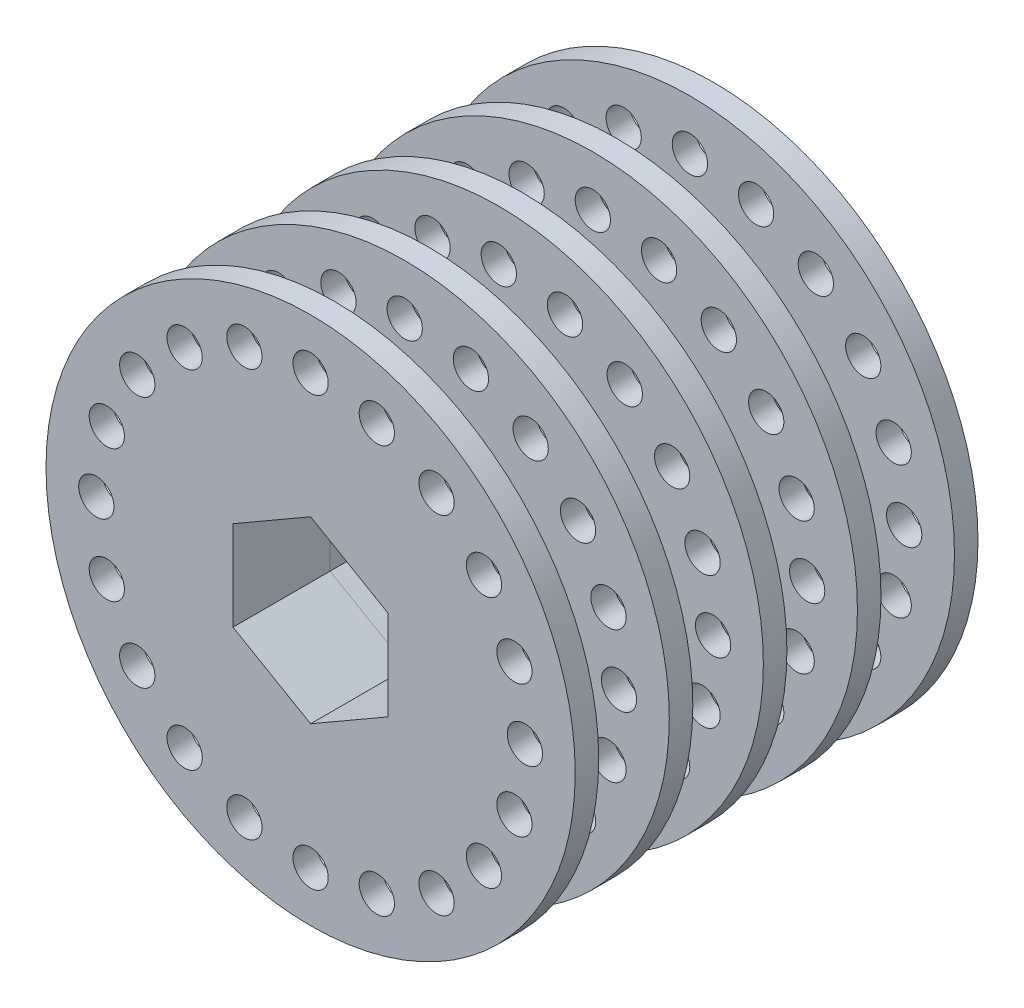
from build123d import *

# Parameters (mm, degrees)
SKETCH1_R           = 22.5
SKETCH1_R_2         = 1.5
BOSS_EXTRUDE1_DEPTH = 2
SKETCH1_3_R         = 10.16
BOSS_EXTRUDE2_DEPTH = 6.25
LPATTERN2_COUNT     = 4
LPATTERN2_PITCH     = 8
BOSS_EXTRUDE3_START = 2
SKETCH2_R           = 22.5
SKETCH2_R_2         = 1.5
BOSS_EXTRUDE3_DEPTH = 2
CUT_EXTRUDE1_DEPTH  = 47.75


with BuildPart() as part:
    # Sketch1 → Boss-Extrude1 (new body)
    with BuildSketch(Plane.XY):
        Circle(SKETCH1_R)
        with Locations((-5.630860181, -17.330005678)):
            Circle(SKETCH1_R_2, mode=Mode.SUBTRACT)
        with Locations((-10.710532534, -14.741783339)):
            Circle(SKETCH1_R_2, mode=Mode.SUBTRACT)
        with Locations((-17.330005678, -5.630860181)):
            Circle(SKETCH1_R_2, mode=Mode.SUBTRACT)
        with Locations((-14.741783339, -10.710532534)):
            Circle(SKETCH1_R_2, mode=Mode.SUBTRACT)
        with Locations((-18.221846316, 0)):
            Circle(SKETCH1_R_2, mode=Mode.SUBTRACT)
        with Locations((0, -18.221846316)):
            Circle(SKETCH1_R_2, mode=Mode.SUBTRACT)
        with Locations((5.630860181, -17.330005678)):
            Circle(SKETCH1_R_2, mode=Mode.SUBTRACT)
        with Locations((10.710532534, -14.741783339)):
            Circle(SKETCH1_R_2, mode=Mode.SUBTRACT)
        with Locations((14.741783339, -10.710532534)):
            Circle(SKETCH1_R_2, mode=Mode.SUBTRACT)
        with Locations((17.330005678, -5.630860181)):
            Circle(SKETCH1_R_2, mode=Mode.SUBTRACT)
        with Locations((-17.330005678, 5.630860181)):
            Circle(SKETCH1_R_2, mode=Mode.SUBTRACT)
        with Locations((-14.741783339, 10.710532534)):
            Circle(SKETCH1_R_2, mode=Mode.SUBTRACT)
        with Locations((-10.710532534, 14.741783339)):
            Circle(SKETCH1_R_2, mode=Mode.SUBTRACT)
        with Locations((-5.630860181, 17.330005678)):
            Circle(SKETCH1_R_2, mode=Mode.SUBTRACT)
        with Locations((5.630860181, 17.330005678)):
            Circle(SKETCH1_R_2, mode=Mode.SUBTRACT)
        with Locations((18.221846316, 0)):
            Circle(SKETCH1_R_2, mode=Mode.SUBTRACT)
        with Locations((14.741783339, 10.710532534)):
            Circle(SKETCH1_R_2, mode=Mode.SUBTRACT)
        with Locations((17.330005678, 5.630860181)):
            Circle(SKETCH1_R_2, mode=Mode.SUBTRACT)
        with Locations((10.710532534, 14.741783339)):
            Circle(SKETCH1_R_2, mode=Mode.SUBTRACT)
        with Locations((0, 18.221846316)):
            Circle(SKETCH1_R_2, mode=Mode.SUBTRACT)
    extrude(amount=BOSS_EXTRUDE1_DEPTH)

    # Sketch1_3 → Boss-Extrude2 (add)
    with BuildSketch(Plane.XY):
        Circle(SKETCH1_3_R)
    extrude(amount=-BOSS_EXTRUDE2_DEPTH)


with BuildPart() as lpattern2_1:
    # LPattern2: pattern copy
    add(part.part.moved(Location(Vector(0, 0, -1) * (1 * LPATTERN2_PITCH))))


with BuildPart() as lpattern2_2:
    # LPattern2: pattern copy
    add(part.part.moved(Location(Vector(0, 0, -1) * (2 * LPATTERN2_PITCH))))


with BuildPart() as lpattern2_3:
    # LPattern2: pattern copy
    add(part.part.moved(Location(Vector(0, 0, -1) * (3 * LPATTERN2_PITCH))))

    # Sketch2 → Boss-Extrude3 (add)
    with BuildSketch(Plane(origin=(0, 0, -30.25), x_dir=(-1, 0, 0), z_dir=(0, 0, -1)).offset(BOSS_EXTRUDE3_START)):
        Circle(SKETCH2_R)
        with Locations((-5.630860181, -17.330005678)):
            Circle(SKETCH2_R_2, mode=Mode.SUBTRACT)
        with Locations((0, -18.221846316)):
            Circle(SKETCH2_R_2, mode=Mode.SUBTRACT)
        with Locations((-10.710532534, -14.741783339)):
            Circle(SKETCH2_R_2, mode=Mode.SUBTRACT)
        with Locations((-17.330005678, -5.630860181)):
            Circle(SKETCH2_R_2, mode=Mode.SUBTRACT)
        with Locations((-14.741783339, -10.710532534)):
            Circle(SKETCH2_R_2, mode=Mode.SUBTRACT)
        with Locations((5.630860181, -17.330005678)):
            Circle(SKETCH2_R_2, mode=Mode.SUBTRACT)
        with Locations((10.710532534, -14.741783339)):
            Circle(SKETCH2_R_2, mode=Mode.SUBTRACT)
        with Locations((14.741783339, -10.710532534)):
            Circle(SKETCH2_R_2, mode=Mode.SUBTRACT)
        with Locations((17.330005678, -5.630860181)):
            Circle(SKETCH2_R_2, mode=Mode.SUBTRACT)
        with Locations((18.221846316, 0)):
            Circle(SKETCH2_R_2, mode=Mode.SUBTRACT)
        with Locations((-18.221846316, 0)):
            Circle(SKETCH2_R_2, mode=Mode.SUBTRACT)
        with Locations((-17.330005678, 5.630860181)):
            Circle(SKETCH2_R_2, mode=Mode.SUBTRACT)
        with Locations((-14.741783339, 10.710532534)):
            Circle(SKETCH2_R_2, mode=Mode.SUBTRACT)
        with Locations((-10.710532534, 14.741783339)):
            Circle(SKETCH2_R_2, mode=Mode.SUBTRACT)
        with Locations((-5.630860181, 17.330005678)):
            Circle(SKETCH2_R_2, mode=Mode.SUBTRACT)
        with Locations((5.630860181, 17.330005678)):
            Circle(SKETCH2_R_2, mode=Mode.SUBTRACT)
        with Locations((14.741783339, 10.710532534)):
            Circle(SKETCH2_R_2, mode=Mode.SUBTRACT)
        with Locations((17.330005678, 5.630860181)):
            Circle(SKETCH2_R_2, mode=Mode.SUBTRACT)
        with Locations((10.710532534, 14.741783339)):
            Circle(SKETCH2_R_2, mode=Mode.SUBTRACT)
        with Locations((0, 18.221846316)):
            Circle(SKETCH2_R_2, mode=Mode.SUBTRACT)
    extrude(amount=-BOSS_EXTRUDE3_DEPTH)


with BuildPart() as cut_extrude1_tool:
    # Sketch3 → Cut-Extrude1 (new, through all)
    with BuildSketch(Plane(origin=(0, 0, -32.25), x_dir=(-1, 0, 0), z_dir=(0, 0, -1))):
        Polygon((6.6, 3.810511777), (0, 7.621023553), (-6.6, 3.810511777), (-6.6, -3.810511777), (0, -7.621023553), (6.6, -3.810511777), align=None)
    extrude(amount=-CUT_EXTRUDE1_DEPTH)


with BuildPart() as part_1:
    add(part.part)

    # Cut-Extrude1: cut by cut_extrude1_tool
    add(cut_extrude1_tool.part, mode=Mode.SUBTRACT)


with BuildPart() as lpattern2_1_1:
    add(lpattern2_1.part)

    # Cut-Extrude1: cut by cut_extrude1_tool
    add(cut_extrude1_tool.part, mode=Mode.SUBTRACT)


with BuildPart() as lpattern2_2_1:
    add(lpattern2_2.part)

    # Cut-Extrude1: cut by cut_extrude1_tool
    add(cut_extrude1_tool.part, mode=Mode.SUBTRACT)


with BuildPart() as lpattern2_3_1:
    add(lpattern2_3.part)

    # Cut-Extrude1: cut by cut_extrude1_tool
    add(cut_extrude1_tool.part, mode=Mode.SUBTRACT)


solid = Compound([part_1.part, lpattern2_1_1.part, lpattern2_2_1.part, lpattern2_3_1.part])
